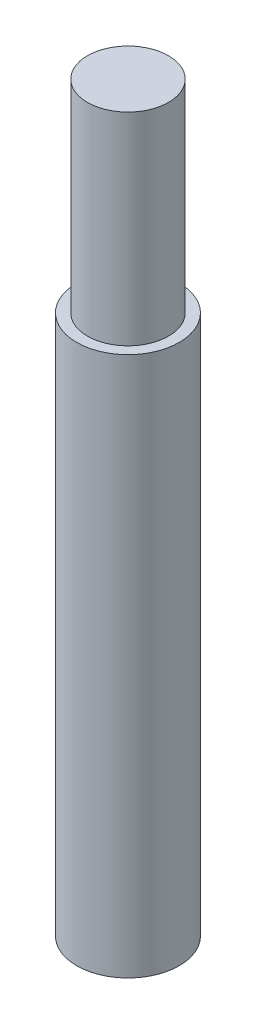
from build123d import *

# Parameters (mm, degrees)
SKETCH1_R           = 2.413
BOSS_EXTRUDE1_DEPTH = 25.4
SKETCH2_R           = 1.905
BOSS_EXTRUDE2_DEPTH = 9.525


with BuildPart() as part:
    # Sketch1 → Boss-Extrude1 (new body)
    with BuildSketch(Plane(origin=(0, 0, 0), x_dir=(1, 0, 0), z_dir=(0, 1, 0))):
        Circle(SKETCH1_R)
    extrude(amount=BOSS_EXTRUDE1_DEPTH)

    # Sketch2 → Boss-Extrude2 (add)
    with BuildSketch(Plane(origin=(0, 25.4, 0), x_dir=(1, 0, 0), z_dir=(0, 1, 0))):
        Circle(SKETCH2_R)
    extrude(amount=BOSS_EXTRUDE2_DEPTH)


solid = part.part
